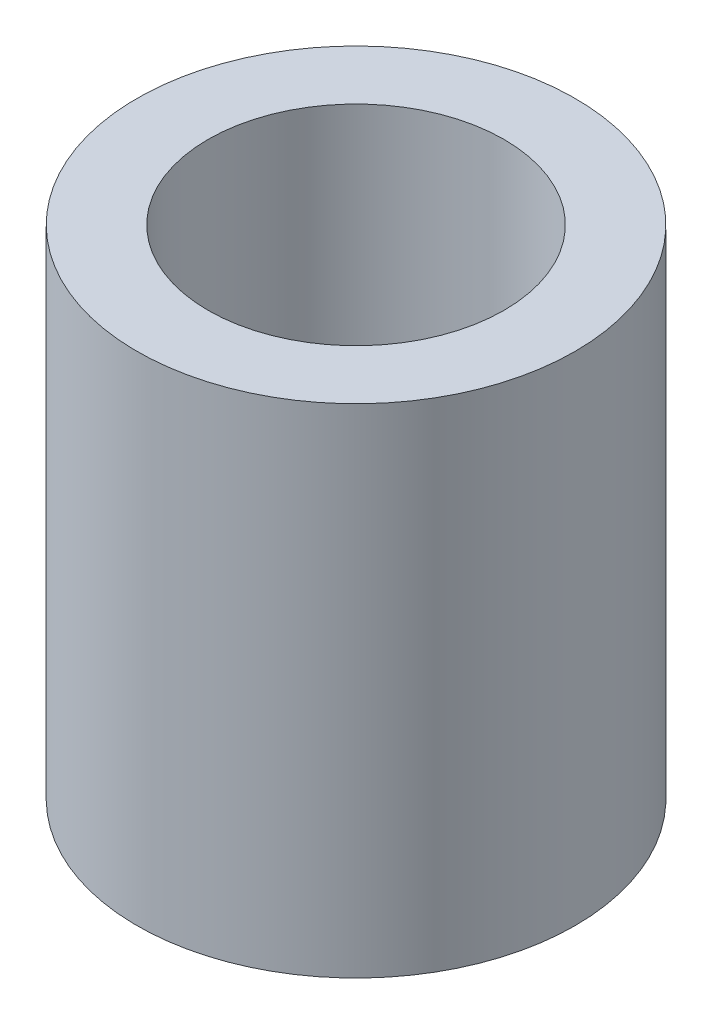
from build123d import *


with BuildPart() as part:
    # Esboço1 → Revolução1 (revolve)
    with BuildSketch(Plane.XY):
        Polygon((-18.5, 0), (0, 0), (0, 14), (-12.5, 14), (-12.5, 42), (-18.5, 42), align=None)
    revolve(axis=Axis((0, -939.995835418, 0), (0, 1, 0)))


solid = part.part
